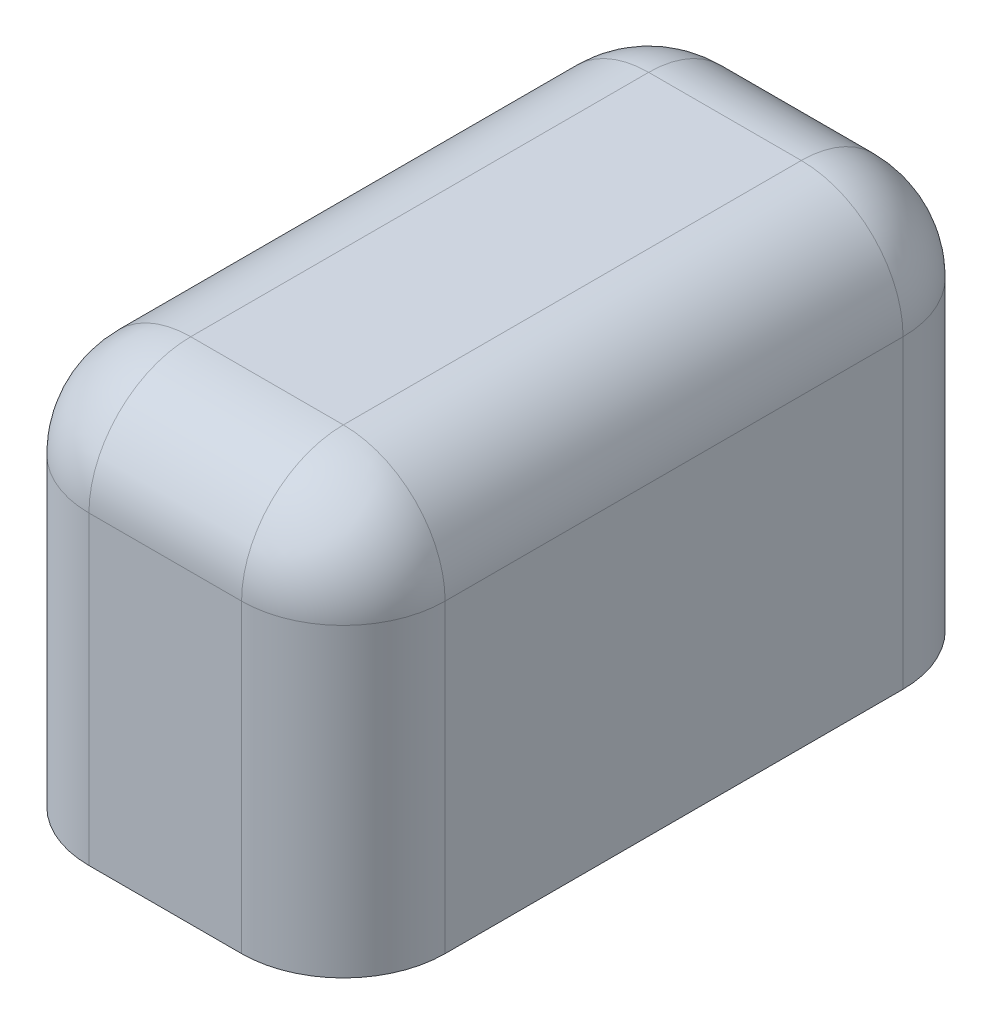
from build123d import *

# Parameters (mm, degrees)
SKETCH1_W           = 16.51
SKETCH1_H           = 10.16
BOSS_EXTRUDE1_DEPTH = 4.445
FILLET1_R           = 2.54


with BuildPart() as part:
    # Sketch1 → Boss-Extrude1 (new body, symmetric)
    with BuildSketch(Plane(origin=(0, 0, 0), x_dir=(0, 0, -1), z_dir=(1, 0, 0))):
        with Locations((8.255, 5.08)):
            Rectangle(SKETCH1_W, SKETCH1_H)
    extrude(amount=BOSS_EXTRUDE1_DEPTH, both=True)

    # Fillet1
    fillet1_edges = [part.edges().sort_by_distance(p)[0] for p in [
        (4.445, 5.08, -16.51),
        (4.445, 10.16, -8.255),
        (4.445, 5.08, 0),
        (-4.445, 10.16, -8.255),
        (-4.445, 5.08, -16.51),
        (-4.445, 5.08, 0),
        (0, 10.16, 0),
        (0, 10.16, -16.51),
    ]]
    fillet(fillet1_edges, radius=FILLET1_R)


solid = part.part
